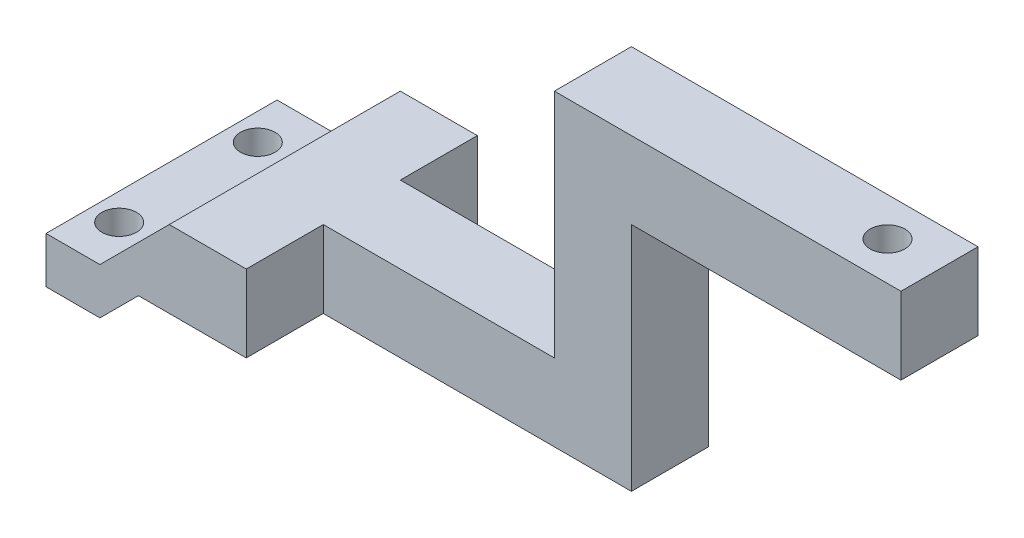
from build123d import *

# Parameters (mm, degrees)
BOSS_EXTRUDE1_DEPTH = 30
CUT_EXTRUDE1_DEPTH  = 10
CUT_EXTRUDE2_DEPTH  = 10
SKETCH5_R           = 2.25
CUT_EXTRUDE3_DEPTH  = 46
SKETCH6_R           = 2.25
CUT_EXTRUDE4_DEPTH  = 10


with BuildPart() as part:
    # Sketch1 → Boss-Extrude1 (new body)
    with BuildSketch(Plane.XY):
        Polygon((0, 0), (0, 6), (7, 6), (16, 15), (56, 15), (56, 45), (101, 45), (101, 35), (66, 35), (66, 5), (12, 5), (7, 0), align=None)
    extrude(amount=BOSS_EXTRUDE1_DEPTH)

    # Sketch2 → Cut-Extrude1 (cut)
    with BuildSketch(Plane.XY.offset(30)):
        Polygon((26, 15), (26, 5), (66, 5), (66, 35), (101, 35), (101, 45), (56, 45), (56, 15), align=None)
    extrude(amount=-CUT_EXTRUDE1_DEPTH, mode=Mode.SUBTRACT)

    # Sketch4 → Cut-Extrude2 (cut)
    with BuildSketch(Plane(origin=(0, 0, 0), x_dir=(-1, 0, 0), z_dir=(0, 0, -1))):
        Polygon((-66, 5), (-26, 5), (-26, 15), (-56, 15), (-56, 45), (-101, 45), (-101, 35), (-66, 35), align=None)
    extrude(amount=-CUT_EXTRUDE2_DEPTH, mode=Mode.SUBTRACT)

    # Sketch5 → Cut-Extrude3 (cut, through all)
    with BuildSketch(Plane(origin=(0, 45, 0), x_dir=(1, 0, 0), z_dir=(0, 1, 0))):
        with Locations((94.248435015, -15)):
            Circle(SKETCH5_R)
    extrude(amount=-CUT_EXTRUDE3_DEPTH, mode=Mode.SUBTRACT)

    # Sketch6 → Cut-Extrude4 (cut)
    with BuildSketch(Plane(origin=(0, 6, 0), x_dir=(1, 0, 0), z_dir=(0, 1, 0))):
        with Locations((3.5, -6)):
            Circle(SKETCH6_R)
        with Locations((3.5, -24)):
            Circle(SKETCH6_R)
    extrude(amount=-CUT_EXTRUDE4_DEPTH, mode=Mode.SUBTRACT)


solid = part.part
